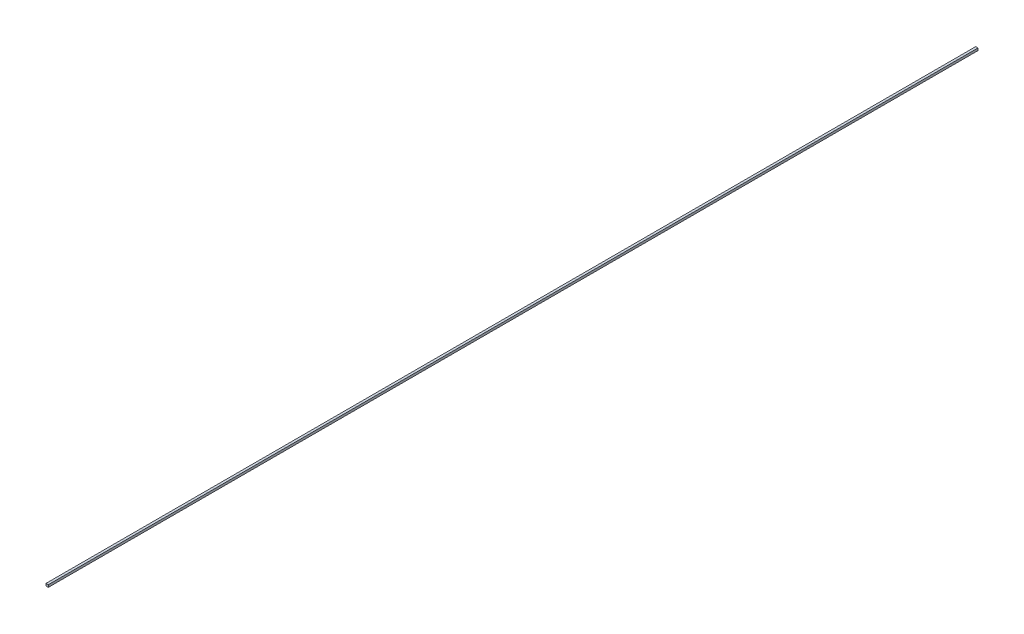
from build123d import *

# Parameters (mm, degrees)
SKETCH1_W           = 3
SKETCH1_H           = 3
BOSS_EXTRUDE1_DEPTH = 1200


with BuildPart() as part:
    # Sketch1 → Boss-Extrude1 (new body)
    with BuildSketch(Plane.XY):
        Rectangle(SKETCH1_W, SKETCH1_H)
    extrude(amount=BOSS_EXTRUDE1_DEPTH)


solid = part.part
